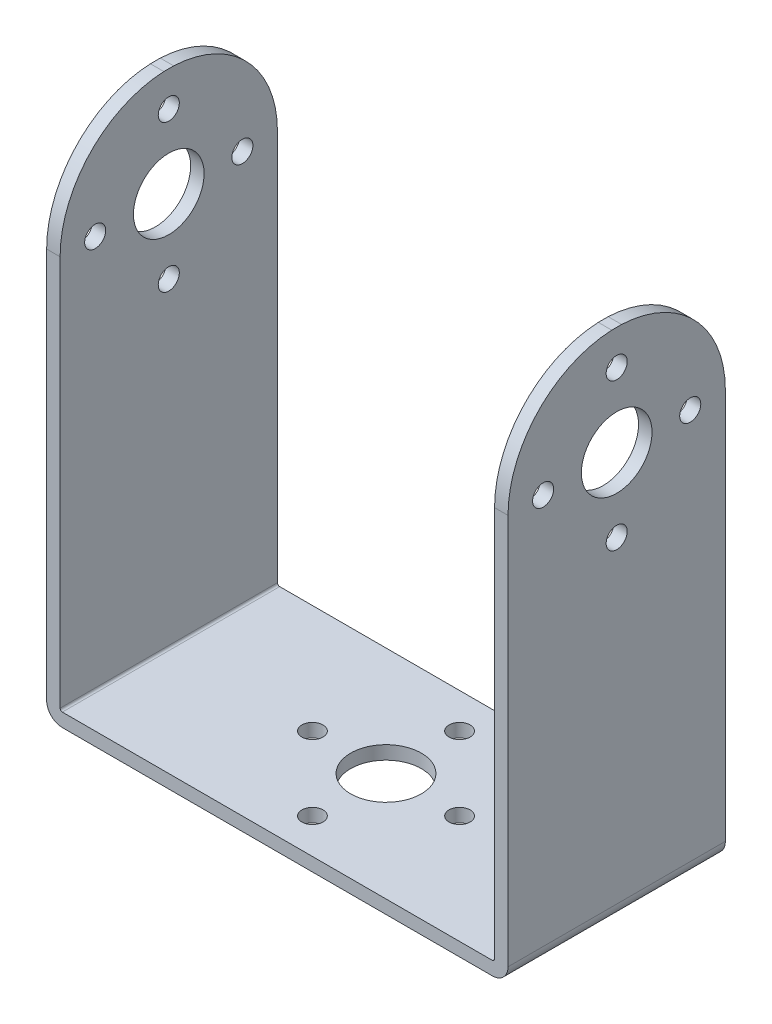
from build123d import *

# Parameters (mm, degrees)
SKETCH1_W               = 49.1998
SKETCH1_H               = 24.6126
SKETCH1_R               = 1.1938
SKETCH1_R_2             = 4.0005
EXTRUDE1_DEPTH          = 1.524
SKETCH1_3_W             = 1.524
SKETCH1_3_H             = 24.6126
EXTRUDE2_DEPTH          = 58.3438
SKETCH4_R               = 4.0005
SKETCH4_R_2             = 1.1938
CUT_EXTRUDE1_DEPTH      = 40.8686
CUT_EXTRUDE1_DEPTH_BACK = 40.8686
FILLET1_R               = 0.254
FILLET2_R               = 1.778


with BuildPart() as part:
    # Sketch1 → Extrude1 (new body)
    with BuildSketch(Plane(origin=(0, 0, 0), x_dir=(1, 0, 0), z_dir=(0, 1, 0))):
        Rectangle(SKETCH1_W, SKETCH1_H)
        with Locations((-8.3312, 0)):
            Circle(SKETCH1_R, mode=Mode.SUBTRACT)
        with Locations((0, -8.3312)):
            Circle(SKETCH1_R, mode=Mode.SUBTRACT)
        Circle(SKETCH1_R_2, mode=Mode.SUBTRACT)
        with Locations((8.3312, 0)):
            Circle(SKETCH1_R, mode=Mode.SUBTRACT)
        with Locations((0, 8.3312)):
            Circle(SKETCH1_R, mode=Mode.SUBTRACT)
    extrude(amount=EXTRUDE1_DEPTH)

    # Sketch1_3 → Extrude2 (add)
    with BuildSketch(Plane(origin=(0, 0, 0), x_dir=(1, 0, 0), z_dir=(0, 1, 0))):
        with Locations((25.3619, 0)):
            Rectangle(SKETCH1_3_W, SKETCH1_3_H)
        with Locations((-25.3619, 0)):
            Rectangle(SKETCH1_3_W, SKETCH1_3_H)
    extrude(amount=EXTRUDE2_DEPTH)

    # Sketch4 → Cut-Extrude1 (cut, two sides)
    with BuildSketch(Plane(origin=(0, 0, 0), x_dir=(0, 0, -1), z_dir=(1, 0, 0))) as cut_extrude1_sk:
        with BuildLine():
            Line((-0.5589443, 58.3438), (-12.3063, 58.3438))
            Line((-12.3063, 58.3438), (-12.3063, 46.0502))
            ThreePointArc((-12.3063, 46.0502), (-8.897290484, 54.552155171), (-0.5589443, 58.3438))
        make_face()
        with BuildLine():
            Line((12.3063, 58.3438), (0.5589443, 58.3438))
            ThreePointArc((0.5589443, 58.3438), (8.897290484, 54.552155171), (12.3063, 46.0502))
            Line((12.3063, 46.0502), (12.3063, 58.3438))
        make_face()
        with Locations((0, 46.0629)):
            Circle(SKETCH4_R)
        with Locations((8.3312, 46.0629)):
            Circle(SKETCH4_R_2)
        with Locations((0, 54.3941)):
            Circle(SKETCH4_R_2)
        with Locations((-8.3312, 46.0629)):
            Circle(SKETCH4_R_2)
        with Locations((0, 37.7317)):
            Circle(SKETCH4_R_2)
    extrude(amount=CUT_EXTRUDE1_DEPTH, mode=Mode.SUBTRACT)
    extrude(cut_extrude1_sk.sketch, amount=-CUT_EXTRUDE1_DEPTH_BACK, mode=Mode.SUBTRACT)

    # Fillet1
    fillet1_edges = [part.edges().sort_by_distance(p)[0] for p in [
        (-24.5999, 1.524, 0),
        (24.5999, 1.524, 0),
    ]]
    fillet(fillet1_edges, radius=FILLET1_R)

    # Fillet2
    fillet2_edges = [part.edges().sort_by_distance(p)[0] for p in [
        (-26.1239, 0, 0),
        (26.1239, 0, 0),
    ]]
    fillet(fillet2_edges, radius=FILLET2_R)


solid = part.part
